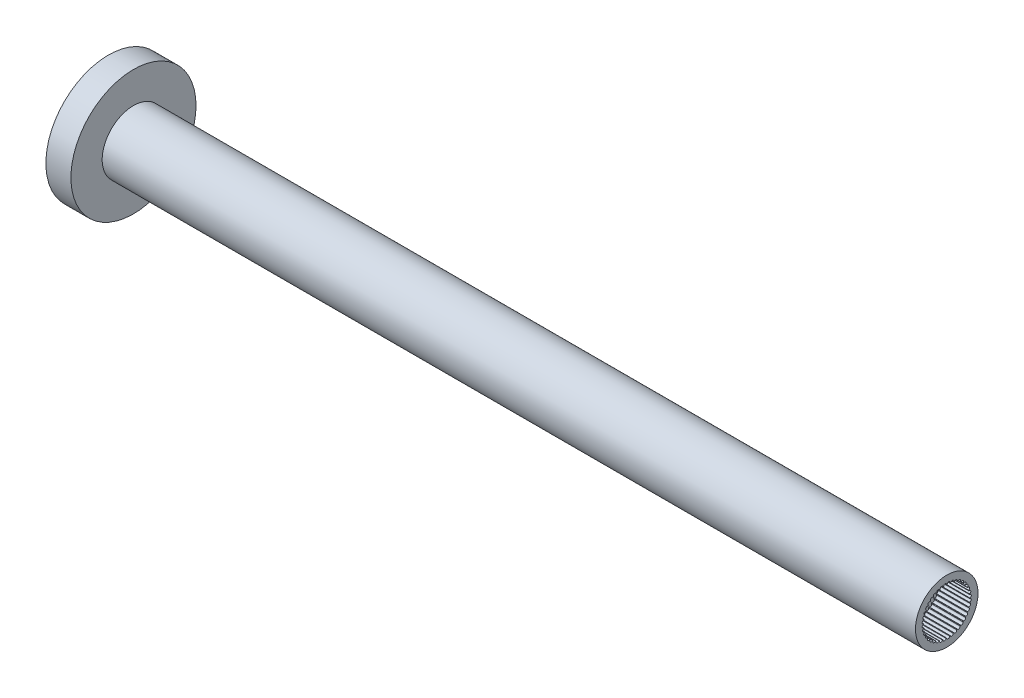
from build123d import *

# Parameters (mm, degrees)
SKETCH1_R           = 6.35
BOSS_EXTRUDE1_DEPTH = 2.54
SKETCH2_R           = 3.175
BOSS_EXTRUDE2_DEPTH = 82.55
SKETCH3_R           = 2.3495
CUT_EXTRUDE1_DEPTH  = 3.175
SKETCH4_R           = 0.1524
CUT_EXTRUDE2_DEPTH  = 3.175


with BuildPart() as part:
    # Sketch1 → Boss-Extrude1 (new body)
    with BuildSketch(Plane(origin=(0, 0, 0), x_dir=(0, 0, -1), z_dir=(1, 0, 0))):
        Circle(SKETCH1_R)
    extrude(amount=BOSS_EXTRUDE1_DEPTH)

    # Sketch2 → Boss-Extrude2 (add)
    with BuildSketch(Plane(origin=(2.54, 0, 0), x_dir=(0, 0, -1), z_dir=(1, 0, 0))):
        Circle(SKETCH2_R)
    extrude(amount=BOSS_EXTRUDE2_DEPTH)

    # Sketch3 → Cut-Extrude1 (cut)
    with BuildSketch(Plane(origin=(85.09, 0, 0), x_dir=(0, 0, -1), z_dir=(1, 0, 0))):
        Circle(SKETCH3_R)
    extrude(amount=-CUT_EXTRUDE1_DEPTH, mode=Mode.SUBTRACT)

    # Sketch4 → Cut-Extrude2 (cut)
    with BuildSketch(Plane(origin=(85.09, 0, 0), x_dir=(0, 0, -1), z_dir=(1, 0, 0))):
        with Locations((1.261294478, 1.982242793)):
            Circle(SKETCH4_R)
        with Locations((1.555856941, 1.760528167)):
            Circle(SKETCH4_R)
        with Locations((1.812109043, 1.495463496)):
            Circle(SKETCH4_R)
        with Locations((2.023741005, 1.19357555)):
            Circle(SKETCH4_R)
        with Locations((2.185541748, 0.862297813)):
            Circle(SKETCH4_R)
        with Locations((2.293527199, 0.509787442)):
            Circle(SKETCH4_R)
        with Locations((2.345038399, 0.144724412)):
            Circle(SKETCH4_R)
        with Locations((2.338806971, -0.223902213)):
            Circle(SKETCH4_R)
        with Locations((2.274986353, -0.587015623)):
            Circle(SKETCH4_R)
        with Locations((2.155148021, -0.93567476)):
            Circle(SKETCH4_R)
        with Locations((1.982242793, -1.261294478)):
            Circle(SKETCH4_R)
        with Locations((1.760528167, -1.555856941)):
            Circle(SKETCH4_R)
        with Locations((1.495463496, -1.812109043)):
            Circle(SKETCH4_R)
        with Locations((1.19357555, -2.023741005)):
            Circle(SKETCH4_R)
        with Locations((0.862297813, -2.185541748)):
            Circle(SKETCH4_R)
        with Locations((0.509787442, -2.293527199)):
            Circle(SKETCH4_R)
        with Locations((0.144724412, -2.345038399)):
            Circle(SKETCH4_R)
        with Locations((-0.223902213, -2.338806971)):
            Circle(SKETCH4_R)
        with Locations((-0.587015623, -2.274986353)):
            Circle(SKETCH4_R)
        with Locations((-0.93567476, -2.155148021)):
            Circle(SKETCH4_R)
        with Locations((-1.261294478, -1.982242793)):
            Circle(SKETCH4_R)
        with Locations((-1.555856941, -1.760528167)):
            Circle(SKETCH4_R)
        with Locations((-1.812109043, -1.495463496)):
            Circle(SKETCH4_R)
        with Locations((-2.023741005, -1.19357555)):
            Circle(SKETCH4_R)
        with Locations((-2.185541748, -0.862297813)):
            Circle(SKETCH4_R)
        with Locations((-2.293527199, -0.509787442)):
            Circle(SKETCH4_R)
        with Locations((-2.345038399, -0.144724412)):
            Circle(SKETCH4_R)
        with Locations((-2.338806971, 0.223902213)):
            Circle(SKETCH4_R)
        with Locations((-2.274986353, 0.587015623)):
            Circle(SKETCH4_R)
        with Locations((-2.155148021, 0.93567476)):
            Circle(SKETCH4_R)
        with Locations((-1.982242793, 1.261294478)):
            Circle(SKETCH4_R)
        with Locations((-1.760528167, 1.555856941)):
            Circle(SKETCH4_R)
        with Locations((-1.495463496, 1.812109043)):
            Circle(SKETCH4_R)
        with Locations((-1.19357555, 2.023741005)):
            Circle(SKETCH4_R)
        with Locations((-0.862297813, 2.185541748)):
            Circle(SKETCH4_R)
        with Locations((-0.509787442, 2.293527199)):
            Circle(SKETCH4_R)
        with Locations((-0.144724412, 2.345038399)):
            Circle(SKETCH4_R)
        with Locations((0.223902213, 2.338806971)):
            Circle(SKETCH4_R)
        with Locations((0.587015623, 2.274986353)):
            Circle(SKETCH4_R)
        with Locations((0.93567476, 2.155148021)):
            Circle(SKETCH4_R)
    extrude(amount=-CUT_EXTRUDE2_DEPTH, mode=Mode.SUBTRACT)


solid = part.part
